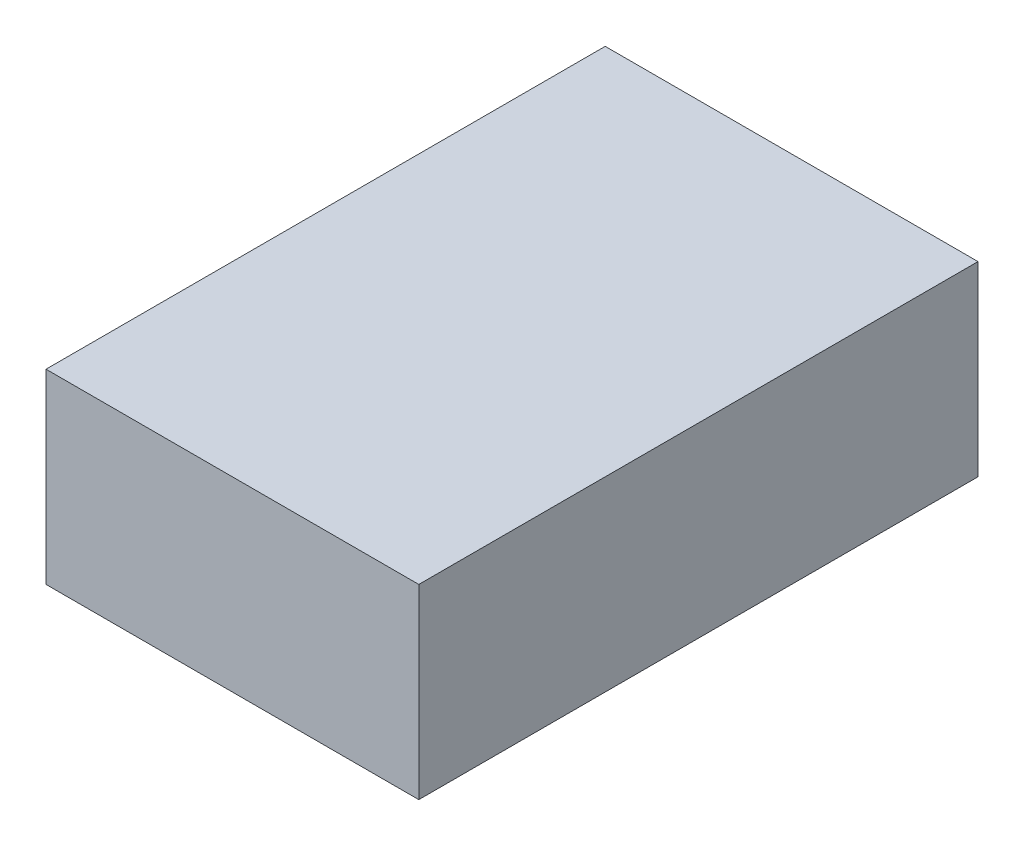
from build123d import *

# Parameters (mm, degrees)
SKETCH1_W           = 200
SKETCH1_H           = 100
BOSS_EXTRUDE1_DEPTH = 300


with BuildPart() as part:
    # Sketch1 → Boss-Extrude1 (new body)
    with BuildSketch(Plane.XY):
        Rectangle(SKETCH1_W, SKETCH1_H)
    extrude(amount=BOSS_EXTRUDE1_DEPTH)


solid = part.part
